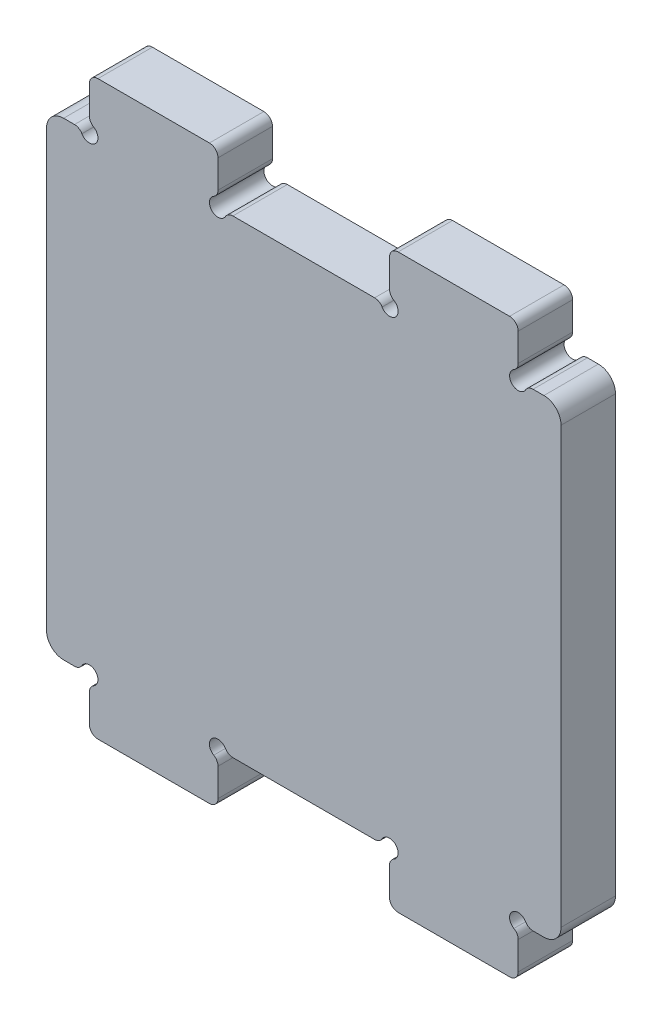
from build123d import *

# Parameters (mm, degrees)
SKETCH1_W               = 60
SKETCH1_H               = 54.7
BOSS_EXTRUDE1_DEPTH     = 6.35
SKETCH2_W               = 15
SKETCH2_H               = 6
BOSS_EXTRUDE2_DEPTH     = 6.35
SKETCH3_R               = 1
CUT_EXTRUDE1_DEPTH      = 7.35
MIRROR2_COPY_1_SKETCH_W = 15
MIRROR2_COPY_1_SKETCH_H = 6
MIRROR2_COPY_1_DEPTH    = 6.35
MIRROR2_COPY_2_SKETCH_R = 1
MIRROR2_COPY_2_DEPTH    = 7.35
FILLET1_R               = 1
FILLET2_R               = 2


with BuildPart() as part:
    # Sketch1 → Boss-Extrude1 (new body)
    with BuildSketch(Plane.XY):
        Rectangle(SKETCH1_W, SKETCH1_H)
    extrude(amount=BOSS_EXTRUDE1_DEPTH)

    # Sketch2 → Boss-Extrude2 (add)
    with BuildSketch(Plane.XY.offset(6.35)):
        with Locations((-17.5, 30.35)):
            Rectangle(SKETCH2_W, SKETCH2_H)
    boss_extrude2 = extrude(amount=-BOSS_EXTRUDE2_DEPTH)

    # Sketch3 → Cut-Extrude1 (cut, through all)
    with BuildSketch(Plane.XY.offset(6.35)):
        with Locations((-25, 27.35)):
            Circle(SKETCH3_R)
        with Locations((-10, 27.35)):
            Circle(SKETCH3_R)
    cut_extrude1 = extrude(amount=-CUT_EXTRUDE1_DEPTH, mode=Mode.SUBTRACT)

    # Mirror1: Boss-Extrude2, Cut-Extrude1 across plane
    add(boss_extrude2.mirror(Plane(origin=(0, 0, 0), x_dir=(0, 0, 1), z_dir=(1, 0, 0))))
    add(cut_extrude1.mirror(Plane(origin=(0, 0, 0), x_dir=(0, 0, 1), z_dir=(1, 0, 0))), mode=Mode.SUBTRACT)

    # Mirror2: Boss-Extrude2, Cut-Extrude1 across plane
    add(boss_extrude2.mirror(Plane.ZX))
    add(cut_extrude1.mirror(Plane.ZX), mode=Mode.SUBTRACT)

    # Mirror2 copy 1 sketch → Mirror2 copy 1 (add)
    with BuildSketch(Plane(origin=(0, 0, 6.35), x_dir=(-1, 0, 0), z_dir=(0, 0, 1))):
        with Locations((-17.5, 30.35)):
            Rectangle(MIRROR2_COPY_1_SKETCH_W, MIRROR2_COPY_1_SKETCH_H)
    extrude(amount=-MIRROR2_COPY_1_DEPTH)

    # Mirror2 copy 2 sketch → Mirror2 copy 2 (cut, through all)
    with BuildSketch(Plane(origin=(0, 0, 6.35), x_dir=(-1, 0, 0), z_dir=(0, 0, 1))):
        with Locations((-25, 27.35)):
            Circle(MIRROR2_COPY_2_SKETCH_R)
        with Locations((-10, 27.35)):
            Circle(MIRROR2_COPY_2_SKETCH_R)
    extrude(amount=-MIRROR2_COPY_2_DEPTH, mode=Mode.SUBTRACT)

    # Fillet1
    fillet1_edges = [part.edges().sort_by_distance(p)[0] for p in [
        (26, -27.35, 3.175),
        (9, -27.35, 3.175),
        (-10, -33.35, 3.175),
        (-25, -33.35, 3.175),
        (-25, -28.35, 3.175),
        (-10, -28.35, 3.175),
        (-26, -27.35, 3.175),
        (-9, -27.35, 3.175),
        (-25, 33.35, 3.175),
        (-10, 33.35, 3.175),
        (-10, 28.35, 3.175),
        (-25, 28.35, 3.175),
        (-26, 27.35, 3.175),
        (-9, 27.35, 3.175),
        (10, 33.35, 3.175),
        (25, 33.35, 3.175),
        (25, 28.35, 3.175),
        (10, 28.35, 3.175),
        (26, 27.35, 3.175),
        (9, 27.35, 3.175),
        (25, -33.35, 3.175),
        (10, -33.35, 3.175),
        (10, -28.35, 3.175),
        (25, -28.35, 3.175),
    ]]
    fillet(fillet1_edges, radius=FILLET1_R)

    # Fillet2
    fillet2_edges = [part.edges().sort_by_distance(p)[0] for p in [
        (-30, 27.35, 3.175),
        (30, 27.35, 3.175),
        (30, -27.35, 3.175),
        (-30, -27.35, 3.175),
    ]]
    fillet(fillet2_edges, radius=FILLET2_R)


solid = part.part
